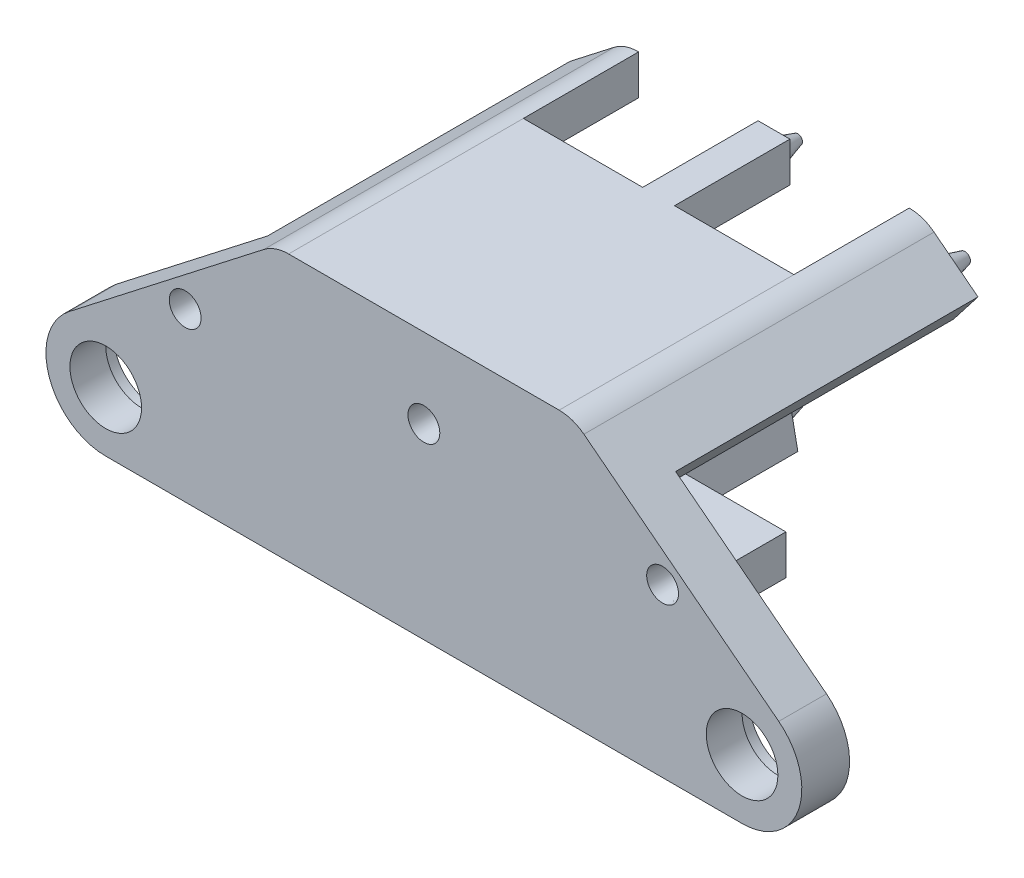
from build123d import *

# Parameters (mm, degrees)
BOSS_EXTRUDE2_DEPTH  = 3
SKETCH3_R            = 4.5
CUT_EXTRUDE3_DEPTH   = 8
SKETCH4_R            = 5
CUT_EXTRUDE4_DEPTH   = 1.5
BOSS_EXTRUDE3_DEPTH  = 20.5
BOSS_EXTRUDE4_DEPTH  = 38
BOSS_EXTRUDE5_DEPTH  = 17.5
SKETCH10_R           = 1.5
BOSS_EXTRUDE6_DEPTH  = 3
BOSS_EXTRUDE6_TAPER  = 15
SKETCH11_R           = 2
CUT_EXTRUDE6_DEPTH   = 3
CUT_EXTRUDE6_TAPER   = 6
SKETCH12_W           = 12.8
SKETCH12_H           = 5
BOSS_EXTRUDE11_DEPTH = 3
SKETCH13_W           = 34
SKETCH13_H           = 5
BOSS_EXTRUDE12_DEPTH = 3
SKETCH9_R            = 1
CUT_EXTRUDE5_DEPTH   = 5
SKETCH15_W           = 4
SKETCH15_H           = 2.5
CUT_EXTRUDE7_DEPTH   = 10
SKETCH16_W           = 4
SKETCH16_H           = 5
BOSS_EXTRUDE13_DEPTH = 14.5
SKETCH17_R           = 1.5
BOSS_EXTRUDE14_DEPTH = 3
BOSS_EXTRUDE14_TAPER = 17


with BuildPart() as part:
    # Sketch1 → Boss-Extrude2 (new body, symmetric)
    with BuildSketch(Plane.XY):
        with BuildLine():
            Line((-44.599094606, 4.924384255), (-20.111639684, 23.933975293))
            ThreePointArc((-20.111639684, 23.933975293), (-18.64459039, 24.726101678), (-17, 25))
            Line((-17, 25), (17, 25))
            ThreePointArc((17, 25), (18.64459039, 24.726101678), (20.111639684, 23.933975293))
            Line((20.111639684, 23.933975293), (44.599094606, 4.924384255))
            ThreePointArc((44.599094606, 4.924384255), (47.095170256, -3.430752773), (40, -8.5))
            Line((40, -8.5), (-40, -8.5))
            ThreePointArc((-40, -8.5), (-47.095170256, -3.430752773), (-44.599094606, 4.924384255))
        make_face()
    extrude(amount=BOSS_EXTRUDE2_DEPTH, both=True)

    # Sketch3 → Cut-Extrude3 (cut)
    with BuildSketch(Plane(origin=(0, 0, -3), x_dir=(-1, 0, 0), z_dir=(0, 0, -1))):
        with Locations((-39.987497786, -1.00001042)):
            Circle(SKETCH3_R)
    cut_extrude3 = extrude(amount=-CUT_EXTRUDE3_DEPTH, mode=Mode.SUBTRACT)

    # Sketch4 → Cut-Extrude4 (cut)
    with BuildSketch(Plane(origin=(0, 0, -3), x_dir=(-1, 0, 0), z_dir=(0, 0, -1))):
        with Locations((-39.987497786, -1.00001042)):
            Circle(SKETCH4_R)
    cut_extrude4 = extrude(amount=-CUT_EXTRUDE4_DEPTH, mode=Mode.SUBTRACT)

    # Mirror1: Cut-Extrude3, Cut-Extrude4 across plane
    add(cut_extrude3.mirror(Plane(origin=(0, 0, 0), x_dir=(0, 0, 1), z_dir=(1, 0, 0))), mode=Mode.SUBTRACT)
    add(cut_extrude4.mirror(Plane(origin=(0, 0, 0), x_dir=(0, 0, 1), z_dir=(1, 0, 0))), mode=Mode.SUBTRACT)

    # Sketch5 → Boss-Extrude3 (add)
    with BuildSketch(Plane(origin=(0, 0, -3), x_dir=(-1, 0, 0), z_dir=(0, 0, -1))):
        Polygon((-17, 25), (17, 25), (17, 20), (2, 20), (2, -3.5), (16, -3.5), (16, -8.5), (-16, -8.5), (-16, -3.5), (-2, -3.5), (-2, 20), (-17, 20), align=None)
    extrude(amount=BOSS_EXTRUDE3_DEPTH)

    # Sketch7 → Boss-Extrude4 (add)
    with BuildSketch(Plane(origin=(0, 0, -3), x_dir=(-1, 0, 0), z_dir=(0, 0, -1))):
        with BuildLine():
            Line((17, 20), (22.575001918, 15.691897491))
            Line((22.575001918, 15.691897491), (25.641064989, 19.641486995))
            Line((25.641064989, 19.641486995), (20.111639684, 23.933975293))
            ThreePointArc((20.111639684, 23.933975293), (18.64459039, 24.726101678), (17, 25))
            Line((17, 25), (17, 20))
        make_face()
    boss_extrude4 = extrude(amount=BOSS_EXTRUDE4_DEPTH)

    # Mirror2: Boss-Extrude4 across plane
    add(boss_extrude4.mirror(Plane(origin=(0, 0, 0), x_dir=(0, 0, 1), z_dir=(1, 0, 0))))

    # Sketch8 → Boss-Extrude5 (add)
    with BuildSketch(Plane(origin=(0, 0, -23.5), x_dir=(-1, 0, 0), z_dir=(0, 0, -1))):
        Polygon((0, -8.5), (3, -8.5), (2, -3.5), (-2, -3.5), (-3, -8.5), align=None)
    extrude(amount=BOSS_EXTRUDE5_DEPTH)

    # Sketch10 → Boss-Extrude6 (add)
    with BuildSketch(Plane(origin=(0, 0, -41), x_dir=(-1, 0, 0), z_dir=(0, 0, -1))):
        with Locations((21, 20.079456047)):
            Circle(SKETCH10_R)
        with Locations((0, -6)):
            Circle(SKETCH10_R)
    boss_extrude6 = extrude(amount=BOSS_EXTRUDE6_DEPTH, taper=BOSS_EXTRUDE6_TAPER)

    # Mirror3: Boss-Extrude6 across plane
    add(boss_extrude6.mirror(Plane(origin=(0, 0, 0), x_dir=(0, 0, 1), z_dir=(1, 0, 0))))

    # Sketch11 → Cut-Extrude6 (cut)
    with BuildSketch(Plane.XY.offset(3)):
        with Locations((0, 15)):
            Circle(SKETCH11_R)
        with Locations((30, 12.5)):
            Circle(SKETCH11_R)
        with Locations((-30, 12.5)):
            Circle(SKETCH11_R)
    extrude(amount=-CUT_EXTRUDE6_DEPTH, taper=CUT_EXTRUDE6_TAPER, mode=Mode.SUBTRACT)

    # Sketch12 → Boss-Extrude11 (add)
    with BuildSketch(Plane(origin=(0, 0, -23.5), x_dir=(-1, 0, 0), z_dir=(0, 0, -1))):
        with Locations((-9.6, -6)):
            Rectangle(SKETCH12_W, SKETCH12_H)
    boss_extrude11 = extrude(amount=BOSS_EXTRUDE11_DEPTH)

    # Mirror4: Boss-Extrude11 across plane
    add(boss_extrude11.mirror(Plane(origin=(0, 0, 0), x_dir=(0, 0, 1), z_dir=(1, 0, 0))))

    # Sketch13 → Boss-Extrude12 (add)
    with BuildSketch(Plane(origin=(0, 0, -23.5), x_dir=(-1, 0, 0), z_dir=(0, 0, -1))):
        with Locations((0, 22.5)):
            Rectangle(SKETCH13_W, SKETCH13_H)
    extrude(amount=BOSS_EXTRUDE12_DEPTH)

    # Sketch9 → Cut-Extrude5 (cut)
    with BuildSketch(Plane(origin=(0, 0, -23.5), x_dir=(-1, 0, 0), z_dir=(0, 0, -1))):
        with Locations((-9.85, -6)):
            Circle(SKETCH9_R)
        with Locations((-9.85, 22.2)):
            Circle(SKETCH9_R)
        with Locations((9.85, 22.2)):
            Circle(SKETCH9_R)
        with Locations((9.85, -6)):
            Circle(SKETCH9_R)
    extrude(amount=CUT_EXTRUDE5_DEPTH, mode=Mode.SUBTRACT)

    # Sketch15 → Cut-Extrude7 (cut)
    with BuildSketch(Plane.XZ.offset(8.5)):
        with Locations((-9.85, -15.82)):
            Rectangle(SKETCH15_W, SKETCH15_H)
        with Locations((9.85, -15.82)):
            Rectangle(SKETCH15_W, SKETCH15_H)
    extrude(amount=-CUT_EXTRUDE7_DEPTH, mode=Mode.SUBTRACT)

    # Sketch16 → Boss-Extrude13 (add)
    with BuildSketch(Plane(origin=(0, 0, -26.5), x_dir=(-1, 0, 0), z_dir=(0, 0, -1))):
        with Locations((0, 22.5)):
            Rectangle(SKETCH16_W, SKETCH16_H)
    extrude(amount=BOSS_EXTRUDE13_DEPTH)

    # Sketch17 → Boss-Extrude14 (add)
    with BuildSketch(Plane(origin=(0, 0, -41), x_dir=(-1, 0, 0), z_dir=(0, 0, -1))):
        with Locations((0, 22.5)):
            Circle(SKETCH17_R)
    extrude(amount=BOSS_EXTRUDE14_DEPTH, taper=BOSS_EXTRUDE14_TAPER)


solid = part.part
